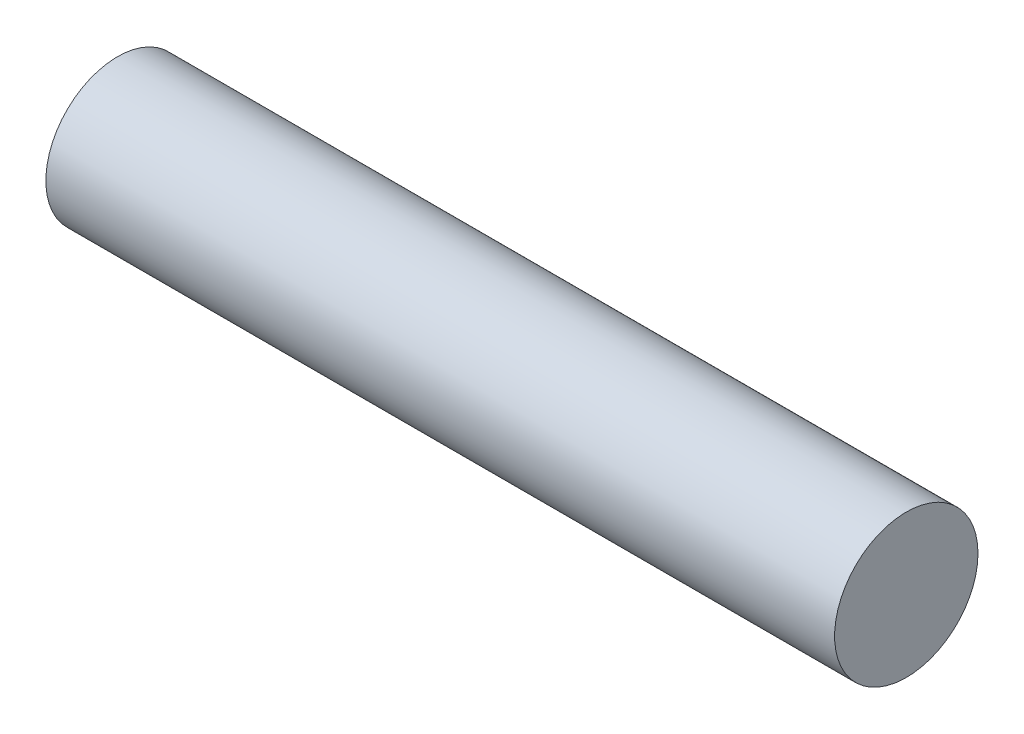
from build123d import *

# Parameters (mm, degrees)
SKETCH_1_R      = 1.5
EXTRUDE_1_DEPTH = 16.5


with BuildPart() as part:
    # 草图1 → 凸台-拉伸1 (new body)
    with BuildSketch(Plane(origin=(0, 0, 0), x_dir=(0, 0, -1), z_dir=(1, 0, 0))):
        Circle(SKETCH_1_R)
    extrude(amount=EXTRUDE_1_DEPTH)


solid = part.part
